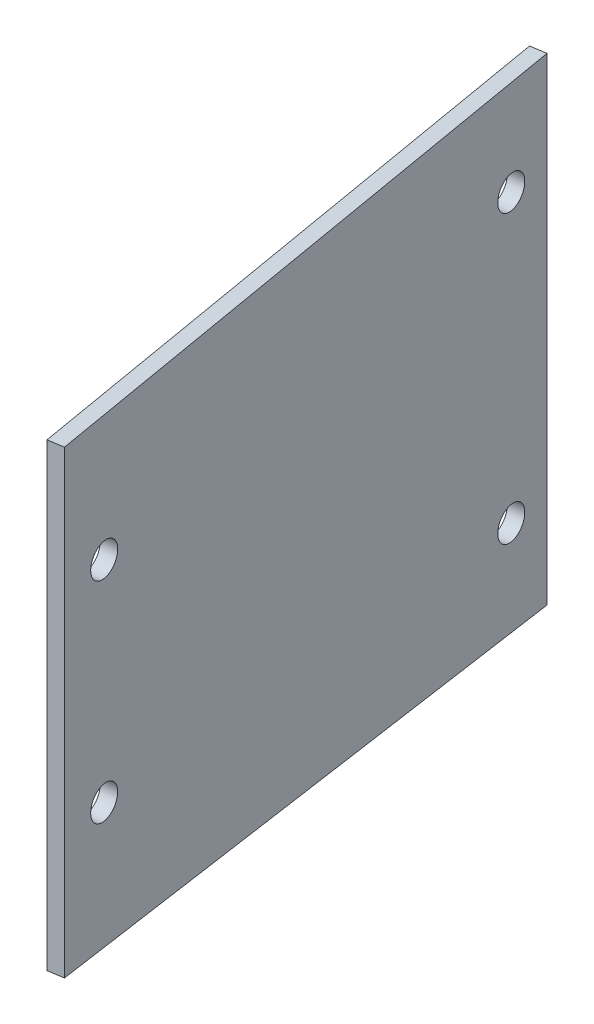
from build123d import *

# Parameters (mm, degrees)
BOSS_EXTRUDE1_DEPTH    = 1.6
BACK_MOUNTING_HOLES_R  = 1.7
CUT_EXTRUDE1_DEPTH     = 11.983113317
FRONT_MOUNTING_HOLES_R = 1.7
CUT_EXTRUDE2_DEPTH     = 11.983113317


with BuildPart() as part:
    # Sketch1 → Boss-Extrude1 (new body)
    with BuildSketch(Plane(origin=(-29.019700562, 0, 4.594785922), x_dir=(-0.156385222, 0, -0.987696139), z_dir=(0.987696139, 0, -0.156385222))):
        Polygon((-6.520440675, 24.056053189), (54.226987254, 25), (54.226987254, -25), (-6.520440675, -24.056053189), align=None)
    extrude(amount=BOSS_EXTRUDE1_DEPTH)

    # Back Mounting Holes → Cut-Extrude1 (cut, through all)
    with BuildSketch(Plane(origin=(-29.019700562, 0, 4.594785922), x_dir=(0.156385222, 0, 0.987696139), z_dir=(-0.987696139, 0, 0.156385222))):
        with Locations((1.520440675, -11)):
            Circle(BACK_MOUNTING_HOLES_R)
        with Locations((1.520440675, 11)):
            Circle(BACK_MOUNTING_HOLES_R)
    extrude(amount=-CUT_EXTRUDE1_DEPTH, mode=Mode.SUBTRACT)

    # Front Mounting Holes → Cut-Extrude2 (cut, through all)
    with BuildSketch(Plane(origin=(-29.019700562, 0, 4.594785922), x_dir=(0.156385222, 0, 0.987696139), z_dir=(-0.987696139, 0, 0.156385222))):
        with Locations((-49.726987254, 15)):
            Circle(FRONT_MOUNTING_HOLES_R)
        with Locations((-49.726987254, -15)):
            Circle(FRONT_MOUNTING_HOLES_R)
    extrude(amount=-CUT_EXTRUDE2_DEPTH, mode=Mode.SUBTRACT)


solid = part.part
